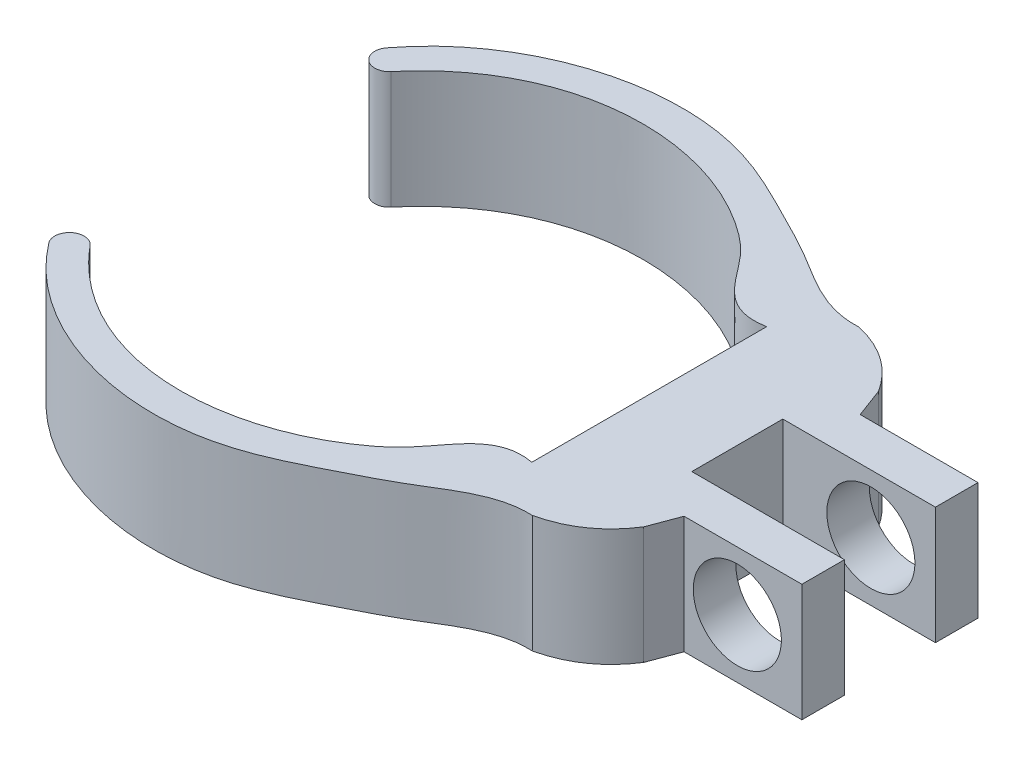
from build123d import *

# Parameters (mm, degrees)
BOSS_EXTRUDE1_DEPTH = 4
SKETCH2_R           = 1.5
CUT_EXTRUDE1_DEPTH  = 10


with BuildPart() as part:
    # Sketch1 → Boss-Extrude1 (new body)
    with BuildSketch(Plane(origin=(0, 0, 0), x_dir=(1, 0, 0), z_dir=(0, 1, 0))):
        with BuildLine():
            Line((0, 8), (0, 0))
            add(Edge.make_bspline(
                [(0, 0), (-1.444972113, 0.268364939), (-1.989778669, -1.274793611), (-5.99641862, -4.532476754), (-11.043579326, -4.596412752), (-13.923421089, -1.125163293)],
                knots=[0, 0, 0, 0, 0.216898357, 0.270831116, 1, 1, 1, 1], degree=3))
            ThreePointArc((-13.923421089, -1.125163293), (-14.628689505, -1.074207804), (-14.679644993, -1.77947622))
            add(Edge.make_bspline(
                [(-14.679644993, -1.77947622), (-12.628894453, -4.474080979), (-7.714296312, -5.95140451), (-3.34534031, -3.74006244), (-1.005631641, -2.560185408), (0.394595325, -1.501153093), (1.579778317, -1.560661502)],
                knots=[0, 0, 0, 0, 0.557352672, 0.711946673, 0.815566185, 1, 1, 1, 1], degree=3))
            add(Edge.make_bspline(
                [(1.579778317, -1.560661502), (3.016371883, -1.23196193), (3.812496302, 0)],
                knots=[0, 0, 0, 1, 1, 1], degree=2))
            Line((3.812496302, 0), (4.185828994, 1))
            Line((4.185828994, 1), (8.2, 1))
            Line((8.2, 1), (8.2, 2.45))
            Line((8.2, 2.45), (3, 2.45))
            Line((3, 2.45), (3, 5.55))
            Line((3, 5.55), (8.2, 5.55))
            Line((8.2, 5.55), (8.2, 7))
            Line((8.2, 7), (4.185828994, 7))
            Line((4.185828994, 7), (3.812496302, 8))
            add(Edge.make_bspline(
                [(1.579778317, 9.560661502), (3.016371883, 9.23196193), (3.812496302, 8)],
                knots=[0, 0, 0, 1, 1, 1], degree=2))
            add(Edge.make_bspline(
                [(-14.679644993, 9.77947622), (-12.628894453, 12.474080979), (-7.714296312, 13.95140451), (-3.34534031, 11.74006244), (-1.005631641, 10.560185408), (0.394595325, 9.501153093), (1.579778317, 9.560661502)],
                knots=[0, 0, 0, 0, 0.557352672, 0.711946673, 0.815566185, 1, 1, 1, 1], degree=3))
            ThreePointArc((-14.679644993, 9.77947622), (-14.628689505, 9.074207804), (-13.923421089, 9.125163293))
            add(Edge.make_bspline(
                [(0, 8), (-1.444972113, 7.731635061), (-1.989778669, 9.274793611), (-5.99641862, 12.532476754), (-11.043579326, 12.596412752), (-13.923421089, 9.125163293)],
                knots=[0, 0, 0, 0, 0.216898357, 0.270831116, 1, 1, 1, 1], degree=3))
        make_face()
    extrude(amount=BOSS_EXTRUDE1_DEPTH)

    # Sketch2 → Cut-Extrude1 (cut)
    with BuildSketch(Plane.XY.offset(-8)):
        with Locations((6, 2)):
            Circle(SKETCH2_R)
    extrude(amount=CUT_EXTRUDE1_DEPTH, mode=Mode.SUBTRACT)


solid = part.part
